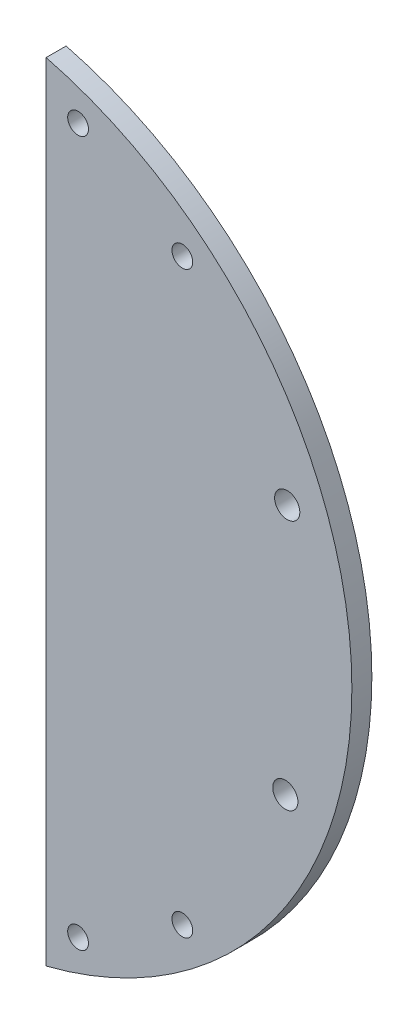
from build123d import *

# Parameters (mm, degrees)
SKETCH1_R           = 1.65
SKETCH1_R_2         = 2
BOSS_EXTRUDE1_DEPTH = 3.175


with BuildPart() as part:
    # Sketch1 → Boss-Extrude1 (new body)
    with BuildSketch(Plane(origin=(0, 0, 0), x_dir=(-1, 0, 0), z_dir=(0, 0, 1))):
        with BuildLine():
            Line((0, -62.136729163), (0, 62.869580678))
            ThreePointArc((0, 62.869580678), (-48.575, 0.366425758), (0, -62.136729163))
        make_face()
        with Locations((-5.075, 56.366425758)):
            Circle(SKETCH1_R, mode=Mode.SUBTRACT)
        with Locations((-21.638471196, 46.366425758)):
            Circle(SKETCH1_R, mode=Mode.SUBTRACT)
        with Locations((-5.075, -55.633574242)):
            Circle(SKETCH1_R, mode=Mode.SUBTRACT)
        with Locations((-21.638471196, -45.633574242)):
            Circle(SKETCH1_R, mode=Mode.SUBTRACT)
        with Locations((-38, 20.287222228)):
            Circle(SKETCH1_R_2, mode=Mode.SUBTRACT)
        with Locations((-38.301731617, -19.711639731)):
            Circle(SKETCH1_R_2, mode=Mode.SUBTRACT)
    extrude(amount=BOSS_EXTRUDE1_DEPTH)


solid = part.part
